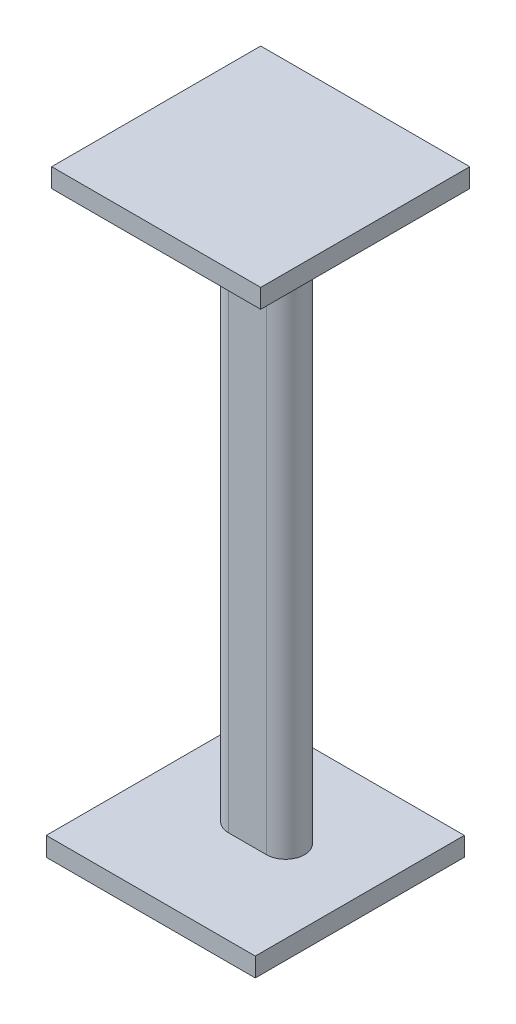
from build123d import *

# Parameters (mm, degrees)
SKETCH1_W           = 419.1
SKETCH1_H           = 419.1
BOSS_EXTRUDE1_DEPTH = 38.1
BOSS_EXTRUDE2_DEPTH = 1117.6
SKETCH6_W           = 419.1
SKETCH6_H           = 419.1
BOSS_EXTRUDE4_DEPTH = 38.1


with BuildPart() as part:
    # Sketch1 → Boss-Extrude1 (new body)
    with BuildSketch(Plane(origin=(0, 0, 0), x_dir=(1, 0, 0), z_dir=(0, 1, 0))):
        with Locations((-182.222860504, 86.904880256)):
            Rectangle(SKETCH1_W, SKETCH1_H)
    extrude(amount=BOSS_EXTRUDE1_DEPTH)

    # Sketch4 → Boss-Extrude2 (add)
    with BuildSketch(Plane(origin=(0, 38.1, 0), x_dir=(1, 0, 0), z_dir=(0, 1, 0))):
        with BuildLine():
            Line((-213.432103513, 140.713298357), (-137.232103513, 140.713298357))
            ThreePointArc((-137.232103513, 140.713298357), (-99.132103513, 102.613298357), (-137.232103513, 64.513298357))
            Line((-137.232103513, 64.513298357), (-213.432103513, 64.513298357))
            ThreePointArc((-213.432103513, 64.513298357), (-251.532103513, 102.613298357), (-213.432103513, 140.713298357))
        make_face()
    extrude(amount=BOSS_EXTRUDE2_DEPTH)

    # Sketch6 → Boss-Extrude4 (add)
    with BuildSketch(Plane(origin=(0, 1155.7, 0), x_dir=(1, 0, 0), z_dir=(0, 1, 0))):
        with Locations((-182.168261088, 97.701559628)):
            Rectangle(SKETCH6_W, SKETCH6_H)
    extrude(amount=BOSS_EXTRUDE4_DEPTH)


solid = part.part
